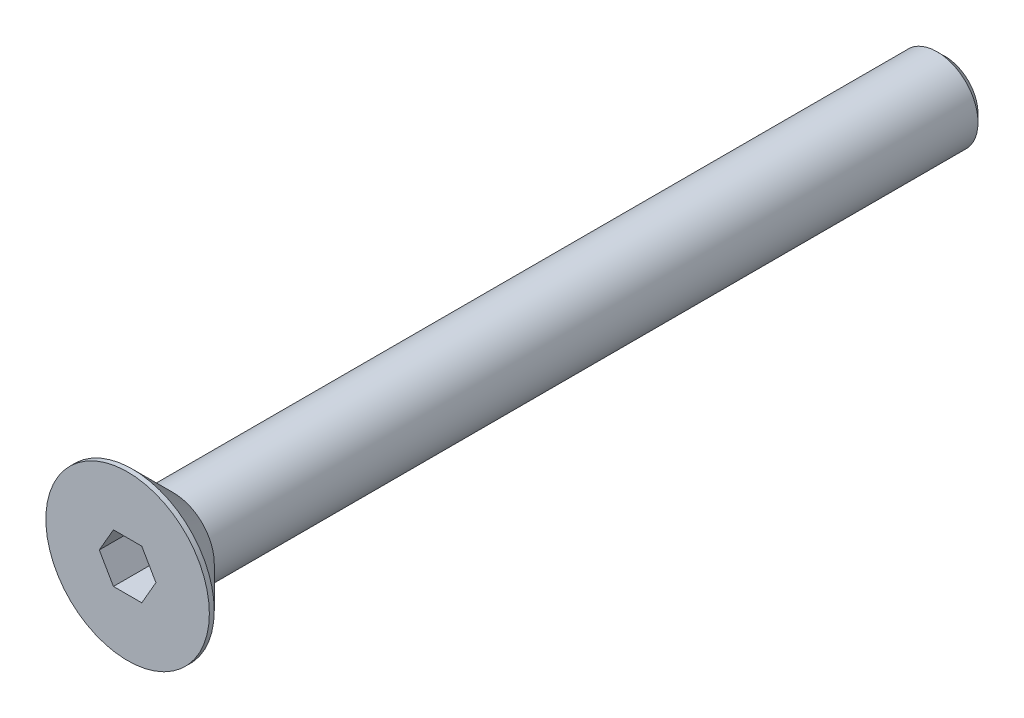
from build123d import *

# Parameters (mm, degrees)
CUT_EXTRUDE1_DEPTH = 3.3
CHAMFER1_SIZE      = 0.49075


with BuildPart() as part:
    # Sketch1 → Revolve1 (revolve)
    with BuildSketch(Plane(origin=(0, 0, 0), x_dir=(1, 0, 0), z_dir=(0, 1, 0))):
        Polygon((2.5, 50), (0, 50), (0, 0), (5, 0), (5, 0.3), (2.5, 2.8), align=None)
    revolve(axis=Axis((0, 0, -50), (0, 0, 1)))

    # Sketch2 → Cut-Extrude1 (cut)
    with BuildSketch(Plane.XY):
        Polygon((-0.866025404, -1.5), (0.866025404, -1.5), (1.732050808, 0), (0.866025404, 1.5), (-0.866025404, 1.5), (-1.732050808, 0), align=None)
    extrude(amount=-CUT_EXTRUDE1_DEPTH, mode=Mode.SUBTRACT)

    # Chamfer1
    chamfer1_edges = [part.edges().sort_by_distance(p)[0] for p in [
        (-2.5, 0, -50),
    ]]
    chamfer(chamfer1_edges, length=CHAMFER1_SIZE)


solid = part.part
